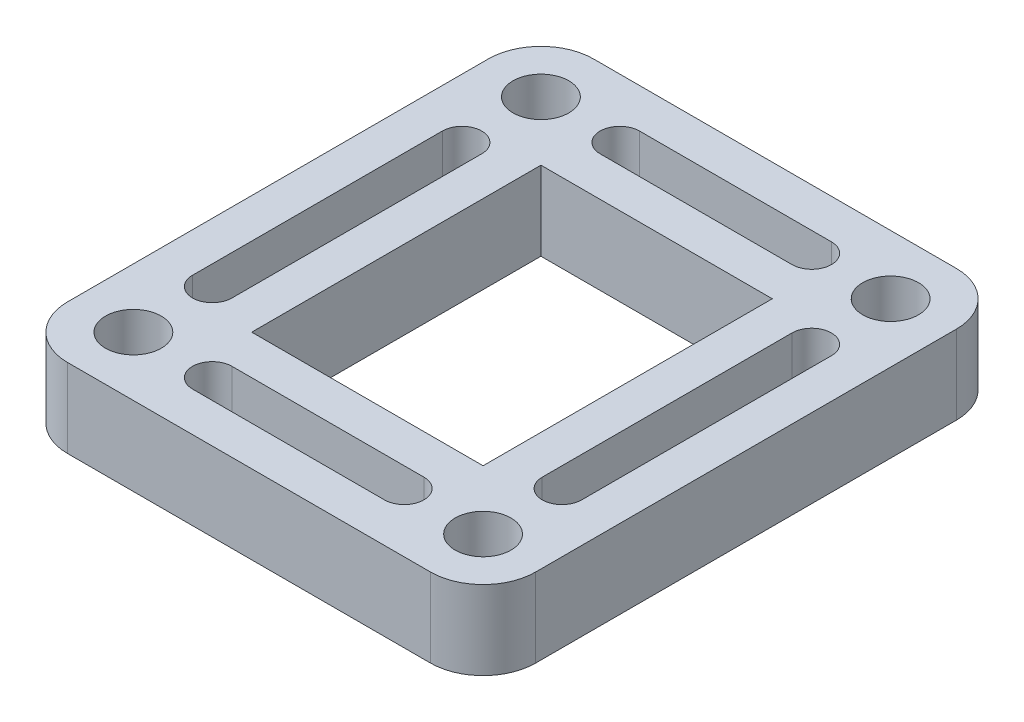
from build123d import *

# Parameters (mm, degrees)
SKETCH1_R           = 2.694076836
SKETCH1_W           = 22.352
SKETCH1_H           = 27.94
BOSS_EXTRUDE1_DEPTH = 7.62


with BuildPart() as part:
    # Sketch1 → Boss-Extrude1 (new body)
    with BuildSketch(Plane(origin=(0, 0, 0), x_dir=(1, 0, 0), z_dir=(0, 1, 0))):
        with BuildLine():
            Line((-22.606, -20.32), (-22.606, 20.32))
            ThreePointArc((-22.606, 20.32), (-21.118102448, 23.912102448), (-17.526, 25.4))
            Line((-17.526, 25.4), (17.526, 25.4))
            ThreePointArc((17.526, 25.4), (21.118102448, 23.912102448), (22.606, 20.32))
            Line((22.606, 20.32), (22.606, -20.32))
            ThreePointArc((22.606, -20.32), (21.118102448, -23.912102448), (17.526, -25.4))
            Line((17.526, -25.4), (-17.526, -25.4))
            ThreePointArc((-17.526, -25.4), (-21.118102448, -23.912102448), (-22.606, -20.32))
        make_face()
        with Locations((16.891, 19.685)):
            Circle(SKETCH1_R, mode=Mode.SUBTRACT)
        with Locations((16.891, -19.685)):
            Circle(SKETCH1_R, mode=Mode.SUBTRACT)
        with Locations((-16.891, -19.685)):
            Circle(SKETCH1_R, mode=Mode.SUBTRACT)
        with Locations((-16.891, 19.685)):
            Circle(SKETCH1_R, mode=Mode.SUBTRACT)
        Rectangle(SKETCH1_W, SKETCH1_H, mode=Mode.SUBTRACT)
        with BuildLine():
            Line((18.796, 12.065), (18.796, -12.065))
            ThreePointArc((18.796, -12.065), (16.891, -13.97), (14.986, -12.065))
            Line((14.986, -12.065), (14.986, 12.065))
            ThreePointArc((14.986, 12.065), (16.891, 13.97), (18.796, 12.065))
        make_face(mode=Mode.SUBTRACT)
        with BuildLine():
            Line((-9.271, -17.78), (9.271, -17.78))
            ThreePointArc((9.271, -17.78), (11.176, -19.685), (9.271, -21.59))
            Line((9.271, -21.59), (-9.271, -21.59))
            ThreePointArc((-9.271, -21.59), (-11.176, -19.685), (-9.271, -17.78))
        make_face(mode=Mode.SUBTRACT)
        with BuildLine():
            Line((-9.271, 17.78), (9.271, 17.78))
            ThreePointArc((9.271, 17.78), (11.176, 19.685), (9.271, 21.59))
            Line((9.271, 21.59), (-9.271, 21.59))
            ThreePointArc((-9.271, 21.59), (-11.176, 19.685), (-9.271, 17.78))
        make_face(mode=Mode.SUBTRACT)
        with BuildLine():
            Line((-18.796, 12.065), (-18.796, -12.065))
            ThreePointArc((-18.796, -12.065), (-16.891, -13.97), (-14.986, -12.065))
            Line((-14.986, -12.065), (-14.986, 12.065))
            ThreePointArc((-14.986, 12.065), (-16.891, 13.97), (-18.796, 12.065))
        make_face(mode=Mode.SUBTRACT)
    extrude(amount=BOSS_EXTRUDE1_DEPTH)


solid = part.part
